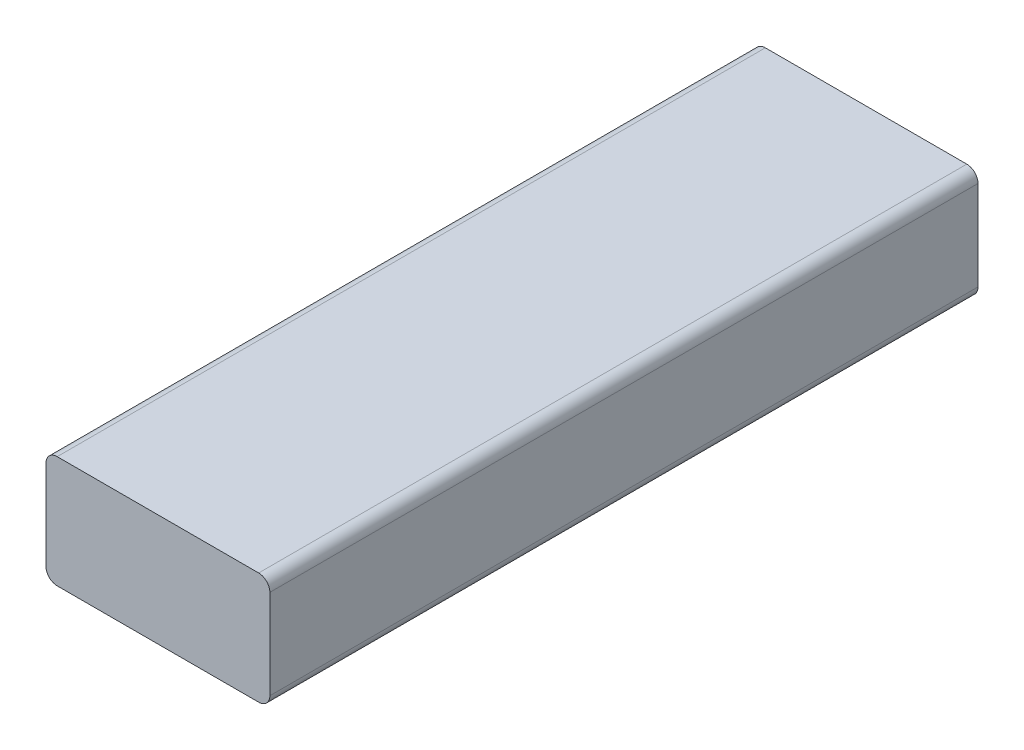
from build123d import *

# Parameters (mm, degrees)
SKETCH1_W           = 101.6
SKETCH1_H           = 321.4
BOSS_EXTRUDE1_DEPTH = 50.8
FILLET1_R           = 5.08


with BuildPart() as part:
    # Sketch1 → Boss-Extrude1 (new body)
    with BuildSketch(Plane(origin=(0, -12.7, 0), x_dir=(-1, 0, 0), z_dir=(0, -1, 0))):
        with Locations((-2536.5, 0)):
            Rectangle(SKETCH1_W, SKETCH1_H)
    extrude(amount=-BOSS_EXTRUDE1_DEPTH)

    # Fillet1
    fillet1_edges = [part.edges().sort_by_distance(p)[0] for p in [
        (2485.7, 38.1, 0),
        (2587.3, 38.1, 0),
        (2485.7, -12.7, 0),
        (2587.3, -12.7, 0),
    ]]
    fillet(fillet1_edges, radius=FILLET1_R)


solid = part.part
